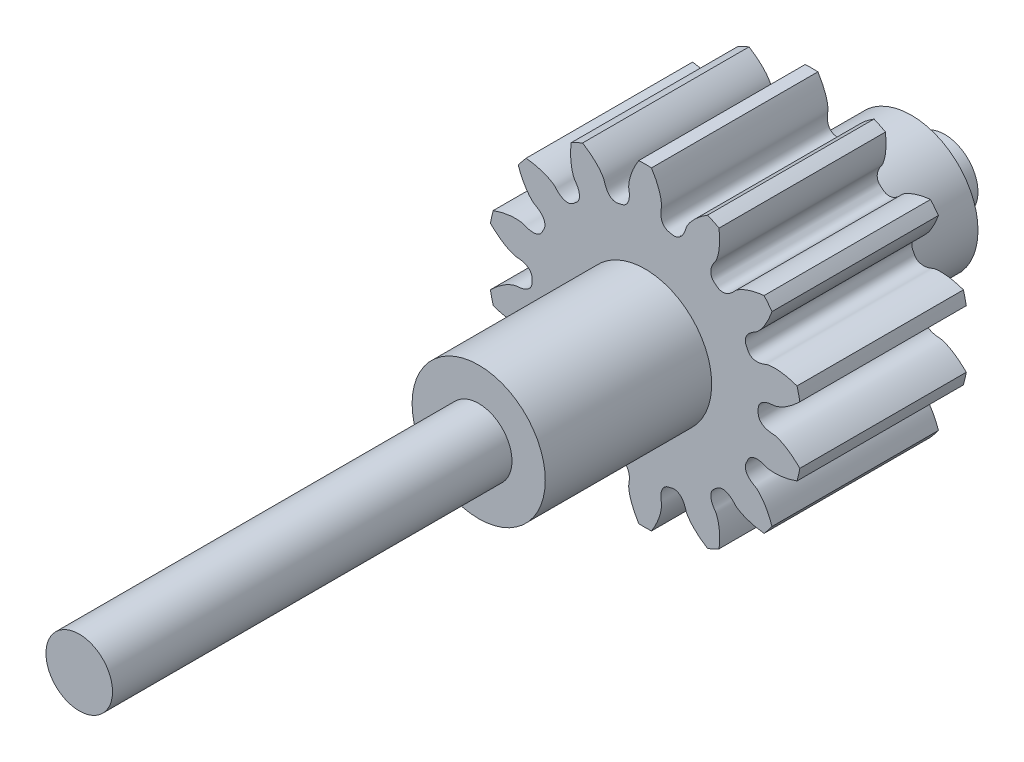
from build123d import *

# Parameters (mm, degrees)
SKETCHREVOLVESPUR02_W                   = 1.25
SKETCHREVOLVESPUR02_H                   = 1.181818182
TOOTHEXTRUDECUTSPUR02_REACH             = 3.832
TOOTHEXTRUDECUTSPUR02_DIRECTION_2_DEPTH = 0.5
PATTERNSPUR02_COUNT                     = 14
CROQUIS1_R                              = 0.5
SALIENTE_EXTRUIR1_DEPTH                 = 0.75
CROQUIS2_R                              = 0.25
SALIENTE_EXTRUIR2_DEPTH                 = 0.25
SALIENTE_EXTRUIR3_START                 = 1.25
CROQUIS3_R                              = 0.5
SALIENTE_EXTRUIR3_DEPTH                 = 1.25
SALIENTE_EXTRUIR4_START                 = 3
CROQUIS4_R                              = 0.25
SALIENTE_EXTRUIR4_DEPTH                 = 3


with BuildPart() as part:
    # SketchRevolveSpur02 → Spur02 (revolve)
    with BuildSketch(Plane(origin=(0, 0, 0), x_dir=(0, 0, -1), z_dir=(1, 0, 0))):
        with Locations((0.125, 0.590909091)):
            Rectangle(SKETCHREVOLVESPUR02_W, SKETCHREVOLVESPUR02_H)
    revolve(axis=Axis((0, 0, 0), (0, 0, -1)))

    # SketchToothSpur02 → ToothExtrudeCutSpur02 (cut, up to next)
    with BuildSketch(Plane.XY, mode=Mode.PRIVATE) as toothextrudecutspur02_sk1:
        with BuildLine():
            ThreePointArc((1.168166232, 0.222699585), (1.189204545, 0), (1.168166232, -0.222699585))
            add(Edge.make_bspline(
                [(1.168166232, -0.222699585), (1.157526693, -0.211684751), (1.141448723, -0.196113102), (1.119536083, -0.177083647), (1.104019508, -0.164539924), (1.089037225, -0.153277276), (1.074659082, -0.143241531), (1.060951743, -0.134375204), (1.047978541, -0.126617668), (1.035799328, -0.11990538), (1.024470395, -0.114171835), (1.014044202, -0.109348446), (1.004569732, -0.105362463), (0.996090914, -0.10214429), (0.988651074, -0.099605674), (0.982279184, -0.097705949), (0.973761475, -0.095361705), (0.964441247, -0.094387793), (0.954328691, -0.094070483), (0.946474335, -0.093365851), (0.938862921, -0.092446816), (0.93149177, -0.091254703), (0.924357399, -0.089804054), (0.917455085, -0.088087315), (0.910779072, -0.086098447), (0.904322788, -0.083825668), (0.898079373, -0.081251883), (0.892042634, -0.078352832), (0.886208703, -0.075095586), (0.880578769, -0.071436934), (0.875163349, -0.067322272), (0.869988625, -0.06268588), (0.865104878, -0.05745421), (0.860596959, -0.051554421), (0.856591364, -0.044931062), (0.853264922, -0.037570367), (0.85080456, -0.029533856), (0.849605179, -0.021771772), (0.849104735, -0.011876995), (0.849659093, 0), (0.849104735, 0.011876995), (0.849605179, 0.021771772), (0.85080456, 0.029533856), (0.853264922, 0.037570367), (0.856591364, 0.044931062), (0.860596959, 0.051554421), (0.865104878, 0.05745421), (0.869988625, 0.06268588), (0.875163349, 0.067322272), (0.880578769, 0.071436934), (0.886208703, 0.075095586), (0.892042634, 0.078352832), (0.898079373, 0.081251883), (0.904322788, 0.083825668), (0.910779072, 0.086098447), (0.917455085, 0.088087315), (0.924357399, 0.089804054), (0.93149177, 0.091254703), (0.938862921, 0.092446816), (0.946474335, 0.093365851), (0.954328691, 0.094070483), (0.964441247, 0.094387793), (0.973761475, 0.095361705), (0.982279184, 0.097705949), (0.988651074, 0.099605674), (0.996090914, 0.10214429), (1.004569732, 0.105362463), (1.014044202, 0.109348446), (1.024470395, 0.114171835), (1.035799328, 0.11990538), (1.047978541, 0.126617668), (1.060951743, 0.134375204), (1.074659082, 0.143241531), (1.089037225, 0.153277276), (1.104019508, 0.164539924), (1.119536083, 0.177083647), (1.141448723, 0.196113102), (1.157526693, 0.211684751), (1.168166232, 0.222699585)],
                knots=[0, 0, 0, 0, 0.055400431, 0.080913787, 0.104969238, 0.127566782, 0.148706421, 0.168388153, 0.186611979, 0.203377899, 0.218685914, 0.232536022, 0.244928224, 0.25586252, 0.265338911, 0.273357395, 0.279917974, 0.297271865, 0.307043535, 0.316542256, 0.325781412, 0.334776637, 0.343546256, 0.352111828, 0.360498786, 0.368737192, 0.376862595, 0.384916961, 0.39294958, 0.401017761, 0.409186971, 0.417529793, 0.426122804, 0.435040151, 0.444342783, 0.454063318, 0.464189245, 0.474650871, 0.48238604, 0.5, 0.51761396, 0.525349129, 0.535810755, 0.545936682, 0.555657217, 0.564959849, 0.573877196, 0.582470207, 0.590813029, 0.598982239, 0.60705042, 0.615083039, 0.623137405, 0.631262808, 0.639501214, 0.647888172, 0.656453744, 0.665223363, 0.674218588, 0.683457744, 0.692956465, 0.702728135, 0.720082026, 0.726642605, 0.734661089, 0.74413748, 0.755071776, 0.767463978, 0.781314086, 0.796622101, 0.813388021, 0.831611847, 0.851293579, 0.872433218, 0.895030762, 0.919086213, 0.944599569, 1, 1, 1, 1], degree=3))
        make_face()
    toothextrudecutspur02_tool1 = extrude(toothextrudecutspur02_sk1.sketch, amount=-TOOTHEXTRUDECUTSPUR02_REACH, mode=Mode.PRIVATE) & part.part
    toothextrudecutspur02 = toothextrudecutspur02_tool1.solids().sort_by_distance((1.052291, 0, 0))[0]
    add(toothextrudecutspur02, mode=Mode.SUBTRACT)

    # SketchToothSpur02 → ToothExtrudeCutSpur02 direction 2 (cut)
    with BuildSketch(Plane.XY):
        with BuildLine():
            ThreePointArc((1.168166232, 0.222699585), (1.189204545, 0), (1.168166232, -0.222699585))
            add(Edge.make_bspline(
                [(1.168166232, -0.222699585), (1.157526693, -0.211684751), (1.141448723, -0.196113102), (1.119536083, -0.177083647), (1.104019508, -0.164539924), (1.089037225, -0.153277276), (1.074659082, -0.143241531), (1.060951743, -0.134375204), (1.047978541, -0.126617668), (1.035799328, -0.11990538), (1.024470395, -0.114171835), (1.014044202, -0.109348446), (1.004569732, -0.105362463), (0.996090914, -0.10214429), (0.988651074, -0.099605674), (0.982279184, -0.097705949), (0.973761475, -0.095361705), (0.964441247, -0.094387793), (0.954328691, -0.094070483), (0.946474335, -0.093365851), (0.938862921, -0.092446816), (0.93149177, -0.091254703), (0.924357399, -0.089804054), (0.917455085, -0.088087315), (0.910779072, -0.086098447), (0.904322788, -0.083825668), (0.898079373, -0.081251883), (0.892042634, -0.078352832), (0.886208703, -0.075095586), (0.880578769, -0.071436934), (0.875163349, -0.067322272), (0.869988625, -0.06268588), (0.865104878, -0.05745421), (0.860596959, -0.051554421), (0.856591364, -0.044931062), (0.853264922, -0.037570367), (0.85080456, -0.029533856), (0.849605179, -0.021771772), (0.849104735, -0.011876995), (0.849659093, 0), (0.849104735, 0.011876995), (0.849605179, 0.021771772), (0.85080456, 0.029533856), (0.853264922, 0.037570367), (0.856591364, 0.044931062), (0.860596959, 0.051554421), (0.865104878, 0.05745421), (0.869988625, 0.06268588), (0.875163349, 0.067322272), (0.880578769, 0.071436934), (0.886208703, 0.075095586), (0.892042634, 0.078352832), (0.898079373, 0.081251883), (0.904322788, 0.083825668), (0.910779072, 0.086098447), (0.917455085, 0.088087315), (0.924357399, 0.089804054), (0.93149177, 0.091254703), (0.938862921, 0.092446816), (0.946474335, 0.093365851), (0.954328691, 0.094070483), (0.964441247, 0.094387793), (0.973761475, 0.095361705), (0.982279184, 0.097705949), (0.988651074, 0.099605674), (0.996090914, 0.10214429), (1.004569732, 0.105362463), (1.014044202, 0.109348446), (1.024470395, 0.114171835), (1.035799328, 0.11990538), (1.047978541, 0.126617668), (1.060951743, 0.134375204), (1.074659082, 0.143241531), (1.089037225, 0.153277276), (1.104019508, 0.164539924), (1.119536083, 0.177083647), (1.141448723, 0.196113102), (1.157526693, 0.211684751), (1.168166232, 0.222699585)],
                knots=[0, 0, 0, 0, 0.055400431, 0.080913787, 0.104969238, 0.127566782, 0.148706421, 0.168388153, 0.186611979, 0.203377899, 0.218685914, 0.232536022, 0.244928224, 0.25586252, 0.265338911, 0.273357395, 0.279917974, 0.297271865, 0.307043535, 0.316542256, 0.325781412, 0.334776637, 0.343546256, 0.352111828, 0.360498786, 0.368737192, 0.376862595, 0.384916961, 0.39294958, 0.401017761, 0.409186971, 0.417529793, 0.426122804, 0.435040151, 0.444342783, 0.454063318, 0.464189245, 0.474650871, 0.48238604, 0.5, 0.51761396, 0.525349129, 0.535810755, 0.545936682, 0.555657217, 0.564959849, 0.573877196, 0.582470207, 0.590813029, 0.598982239, 0.60705042, 0.615083039, 0.623137405, 0.631262808, 0.639501214, 0.647888172, 0.656453744, 0.665223363, 0.674218588, 0.683457744, 0.692956465, 0.702728135, 0.720082026, 0.726642605, 0.734661089, 0.74413748, 0.755071776, 0.767463978, 0.781314086, 0.796622101, 0.813388021, 0.831611847, 0.851293579, 0.872433218, 0.895030762, 0.919086213, 0.944599569, 1, 1, 1, 1], degree=3))
        make_face()
    toothextrudecutspur02_direction_2 = extrude(amount=TOOTHEXTRUDECUTSPUR02_DIRECTION_2_DEPTH, mode=Mode.SUBTRACT)

    # PatternSpur02: ToothExtrudeCutSpur02, ToothExtrudeCutSpur02 direction 2 ×14 about axis
    patternspur02_axis = Axis((0, 0, 55), (0, 0, -1))
    add([toothextrudecutspur02.rotate(patternspur02_axis, i * 360 / PATTERNSPUR02_COUNT) for i in range(1, PATTERNSPUR02_COUNT)], mode=Mode.SUBTRACT)
    add([toothextrudecutspur02_direction_2.rotate(patternspur02_axis, i * 360 / PATTERNSPUR02_COUNT) for i in range(1, PATTERNSPUR02_COUNT)], mode=Mode.SUBTRACT)

    # Croquis1 → Saliente-Extruir1 (add)
    with BuildSketch(Plane(origin=(0, 0, -0.75), x_dir=(-1, 0, 0), z_dir=(0, 0, -1))):
        Circle(CROQUIS1_R)
    extrude(amount=SALIENTE_EXTRUIR1_DEPTH)

    # Croquis2 → Saliente-Extruir2 (add)
    with BuildSketch(Plane(origin=(0, 0, -1.5), x_dir=(-1, 0, 0), z_dir=(0, 0, -1))):
        Circle(CROQUIS2_R)
    extrude(amount=SALIENTE_EXTRUIR2_DEPTH)

    # Croquis3 → Saliente-Extruir3 (add)
    with BuildSketch(Plane.XY.offset(0.5).offset(SALIENTE_EXTRUIR3_START)):
        Circle(CROQUIS3_R)
    extrude(amount=-SALIENTE_EXTRUIR3_DEPTH)

    # Croquis4 → Saliente-Extruir4 (add)
    with BuildSketch(Plane.XY.offset(1.75).offset(SALIENTE_EXTRUIR4_START)):
        Circle(CROQUIS4_R)
    extrude(amount=-SALIENTE_EXTRUIR4_DEPTH)


solid = part.part
